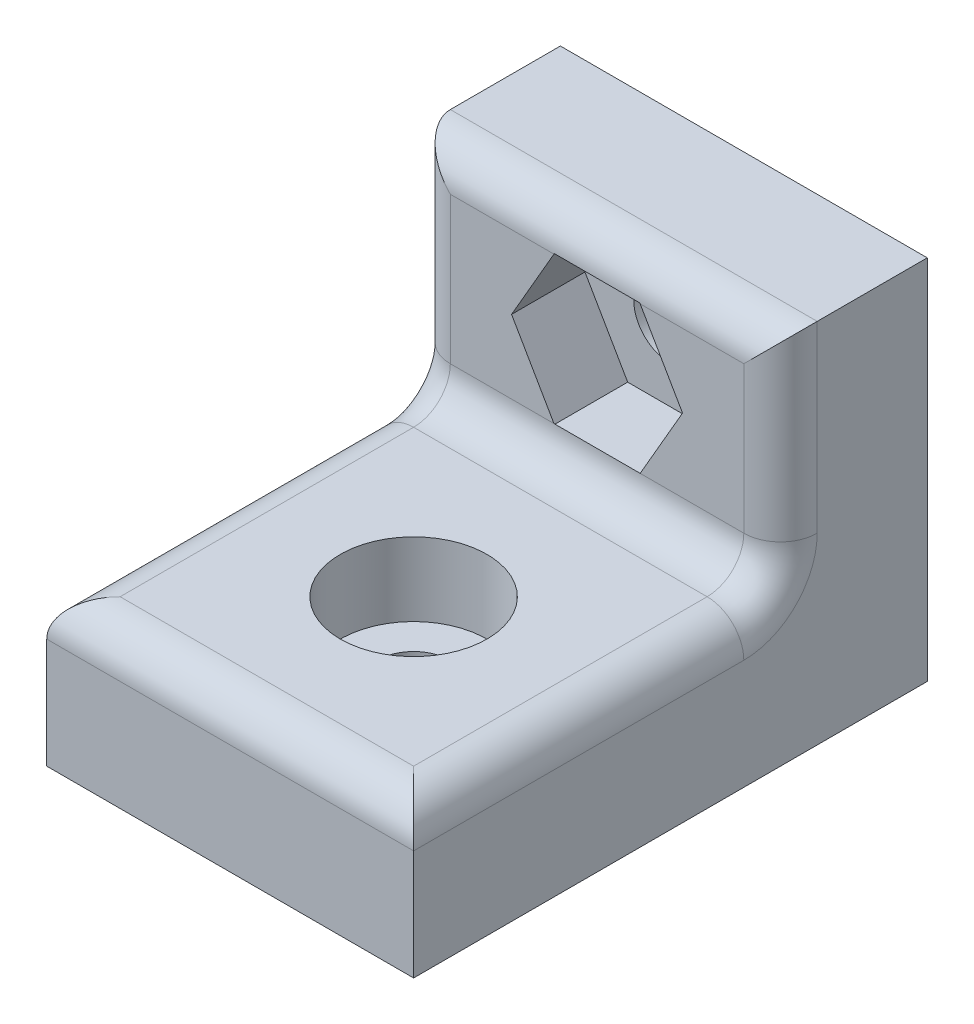
from build123d import *

# Parameters (mm, degrees)
ESQUISSE1_W             = 10
ESQUISSE1_H             = 10
BOSS_EXTRU_1_DEPTH      = 4
ESQUISSE2_W             = 10
ESQUISSE2_H             = 4
BOSS_EXTRU_2_DEPTH      = 10
ESQUISSE3_R             = 1
ENL_V_MAT_EXTRU_1_DEPTH = 5
CONG_1_R                = 1
ESQUISSE4_R             = 1
ENL_V_MAT_EXTRU_2_DEPTH = 5
ENL_V_MAT_EXTRU_3_DEPTH = 2
ESQUISSE6_R             = 2
ENL_V_MAT_EXTRU_4_DEPTH = 2


with BuildPart() as part:
    # Esquisse1 → Boss.-Extru.1 (new body)
    with BuildSketch(Plane.XY):
        with Locations((0, 5)):
            Rectangle(ESQUISSE1_W, ESQUISSE1_H)
    extrude(amount=BOSS_EXTRU_1_DEPTH)

    # Esquisse2 → Boss.-Extru.2 (add)
    with BuildSketch(Plane.XY.offset(4)):
        with Locations((0, 2)):
            Rectangle(ESQUISSE2_W, ESQUISSE2_H)
    extrude(amount=BOSS_EXTRU_2_DEPTH)

    # Esquisse3 → Enlèv. mat.-Extru.1 (cut, through all)
    with BuildSketch(Plane.XY.offset(4)):
        with Locations((0, 7)):
            Circle(ESQUISSE3_R)
    extrude(amount=-ENL_V_MAT_EXTRU_1_DEPTH, mode=Mode.SUBTRACT)

    # Congé1
    cong_1_edges = [part.edges().sort_by_distance(p)[0] for p in [
        (5, 7, 4),
        (-5, 4, 9),
        (0, 4, 4),
        (5, 4, 9),
        (0, 10, 4),
        (0, 4, 14),
        (-5, 7, 4),
    ]]
    fillet(cong_1_edges, radius=CONG_1_R)

    # Esquisse4 → Enlèv. mat.-Extru.2 (cut, through all)
    with BuildSketch(Plane(origin=(0, 4, 0), x_dir=(1, 0, 0), z_dir=(0, 1, 0))):
        with Locations(Location((0, -9, 0), (0, 0, 270))):  # turned: the seam where the file's is
            Circle(ESQUISSE4_R)
    extrude(amount=-ENL_V_MAT_EXTRU_2_DEPTH, mode=Mode.SUBTRACT)

    # Esquisse5 → Enlèv. mat.-Extru.3 (cut)
    with BuildSketch(Plane.XY.offset(4)):
        Polygon((1.165, 4.982160809), (2.33, 7), (1.165, 9.017839191), (-1.165, 9.017839191), (-2.33, 7), (-1.165, 4.982160809), align=None)
    extrude(amount=-ENL_V_MAT_EXTRU_3_DEPTH, mode=Mode.SUBTRACT)

    # Esquisse6 → Enlèv. mat.-Extru.4 (cut)
    with BuildSketch(Plane(origin=(0, 4, 0), x_dir=(1, 0, 0), z_dir=(0, 1, 0))):
        with Locations(Location((0, -9, 0), (0, 0, 270))):  # turned: the seam where the file's is
            Circle(ESQUISSE6_R)
    extrude(amount=-ENL_V_MAT_EXTRU_4_DEPTH, mode=Mode.SUBTRACT)


solid = part.part
